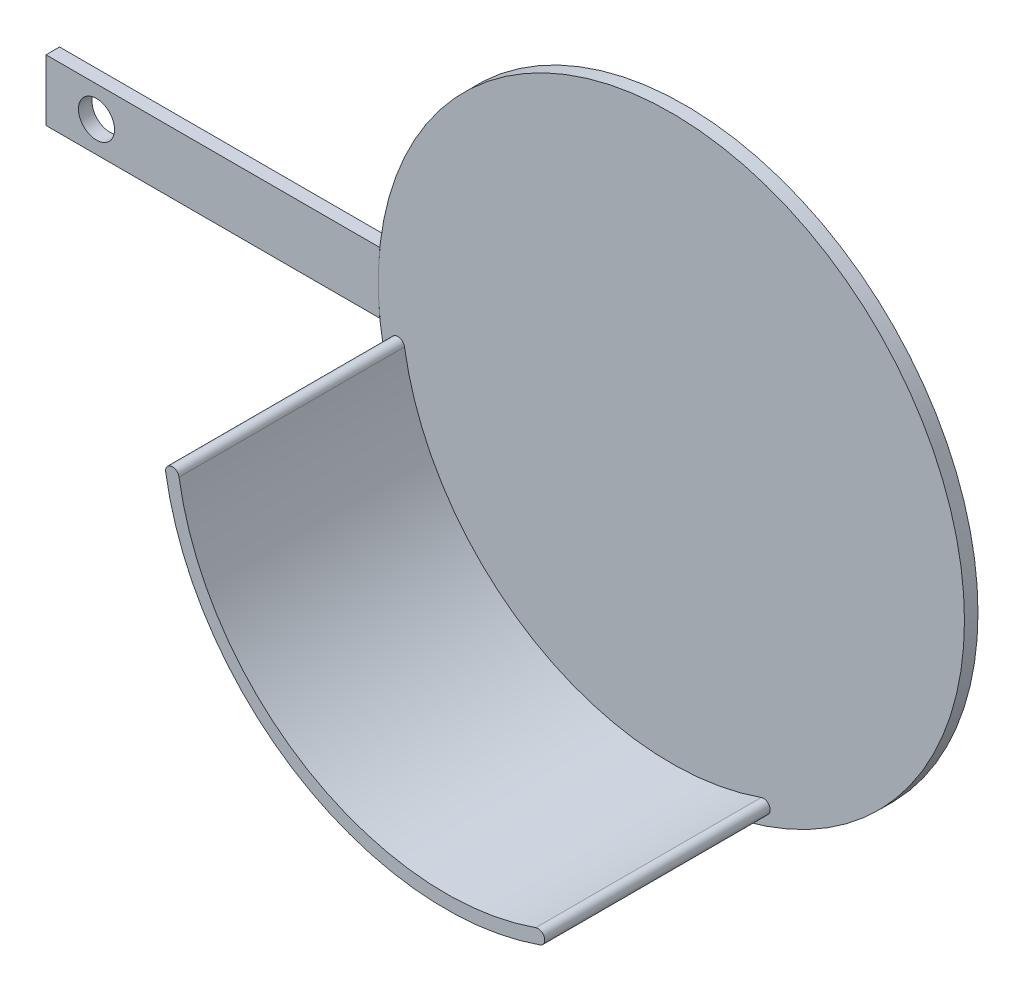
from build123d import *

# Parameters (mm, degrees)
ESQUISSE1_R             = 65
BOSS_EXTRU_1_DEPTH      = 3
BOSS_EXTRU_3_DEPTH      = 3
ESQUISSE4_R             = 4
ENL_V_MAT_EXTRU_1_DEPTH = 3
BOSS_EXTRU_4_DEPTH      = 50


with BuildPart() as part:
    # Esquisse1 → Boss.-Extru.1 (new body)
    with BuildSketch(Plane.XY):
        Circle(ESQUISSE1_R)
    extrude(amount=BOSS_EXTRU_1_DEPTH)

    # Esquisse5 → Boss.-Extru.4 (add)
    with BuildSketch(Plane.XY.offset(3)):
        with BuildLine():
            ThreePointArc((-59.177464872, -9.560867786), (-30.607954016, -51.54159187), (19.92571249, -56.536258483))
            ThreePointArc((19.92571249, -56.536258483), (21.839021079, -57.452364506), (20.922915056, -59.365673094))
            ThreePointArc((20.922915056, -59.365673094), (-32.139760235, -54.121043305), (-62.139061346, -10.039351147))
            ThreePointArc((-62.139061346, -10.039351147), (-60.89750479, -8.31931123), (-59.177464872, -9.560867786))
        make_face()
    extrude(amount=BOSS_EXTRU_4_DEPTH)


with BuildPart() as body_2:
    # Esquisse3 → Boss.-Extru.3 (new body)
    with BuildSketch(Plane(origin=(0, 0, 0), x_dir=(-1, 0, 0), z_dir=(0, 0, -1))):
        with BuildLine():
            Line((64.643923199, 6.794350112), (138.672522355, 6.794350112))
            Line((138.672522355, 6.794350112), (138.672522355, -6.794350112))
            Line((138.672522355, -6.794350112), (64.643923199, -6.794350112))
            ThreePointArc((64.643923199, -6.794350112), (65, 0), (64.643923199, 6.794350112))
        make_face()
    extrude(amount=-BOSS_EXTRU_3_DEPTH)

    # Esquisse4 → Enlèv. mat.-Extru.1 (cut)
    with BuildSketch(Plane.XY.offset(3)):
        with Locations((-127.477067306, 0)):
            Circle(ESQUISSE4_R)
    extrude(amount=-ENL_V_MAT_EXTRU_1_DEPTH, mode=Mode.SUBTRACT)


solid = Compound([part.part, body_2.part])
